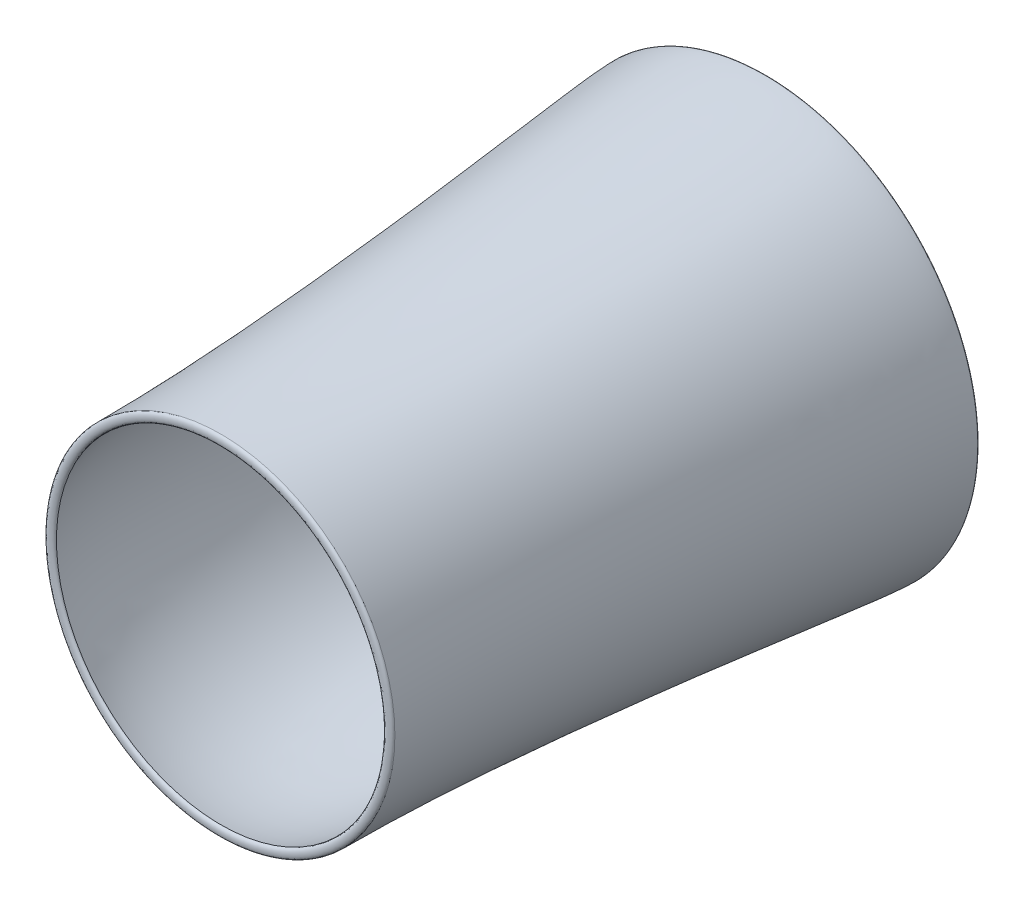
from build123d import *


with BuildPart() as part:
    # Sketch21 → Revolve2 (revolve)
    with BuildSketch(Plane(origin=(0, 0, 0), x_dir=(1, 0, 0), z_dir=(0, 1, 0))):
        with BuildLine():
            Line((-549.937537395, -1834.641614461), (-581.946550206, -1834.641614461))
            add(Edge.make_bspline(
                [(-711.609923736, -15.553973297), (-711.609923736, -140.937925673), (-581.946550206, -1104.332494076), (-581.946550206, -1834.641614461)],
                knots=[0, 0, 0, 0, 1, 1, 1, 1], degree=3))
            Line((-711.609923736, -15.553973297), (-535.765264219, -15.553973297))
            add(Edge.make_bspline(
                [(-535.765264219, -15.553973297), (-621.688080132, -211.883838714), (-472.632532819, -729.064881211), (-643.254530462, -1479.816607803), (-549.937537395, -1834.641614461)],
                knots=[0, 0, 0, 0, 0.206506907, 1, 1, 1, 1], degree=3))
        make_face()
    revolve(axis=Axis((0, 0, 99.684784321), (0, 0, -1)))


with BuildPart() as body_2:
    # Sketch22 → Revolve3 (revolve)
    with BuildSketch(Plane(origin=(0, 0, 0), x_dir=(1, 0, 0), z_dir=(0, 1, 0))):
        with BuildLine():
            Line((-711.609923736, -15.553973297), (-535.765264219, -15.553973297))
            add(Edge.make_bspline(
                [(-711.609923736, -15.553973297), (-711.609923736, 1.379360037), (-535.765264219, 1.379360037), (-535.765264219, -15.553973297)],
                knots=[0, 0, 0, 0, 1, 1, 1, 1], degree=3))
        make_face()
    revolve(axis=Axis((0, 0, 99.684784321), (0, 0, -1)))


with BuildPart() as body_3:
    # Sketch23 → Revolve4 (revolve)
    with BuildSketch(Plane(origin=(0, 0, 0), x_dir=(1, 0, 0), z_dir=(0, 1, 0))):
        with BuildLine():
            Line((-581.946550206, -1834.641614461), (-549.937537395, -1834.641614461))
            add(Edge.make_bspline(
                [(-581.946550206, -1834.641614461), (-581.946550206, -1847.341614461), (-549.937537395, -1847.341614461), (-549.937537395, -1834.641614461)],
                knots=[0, 0, 0, 0, 1, 1, 1, 1], degree=3))
        make_face()
    revolve(axis=Axis((0, 0, 1104.756830123), (0, 0, -1)))


solid = Compound([part.part, body_2.part, body_3.part])
